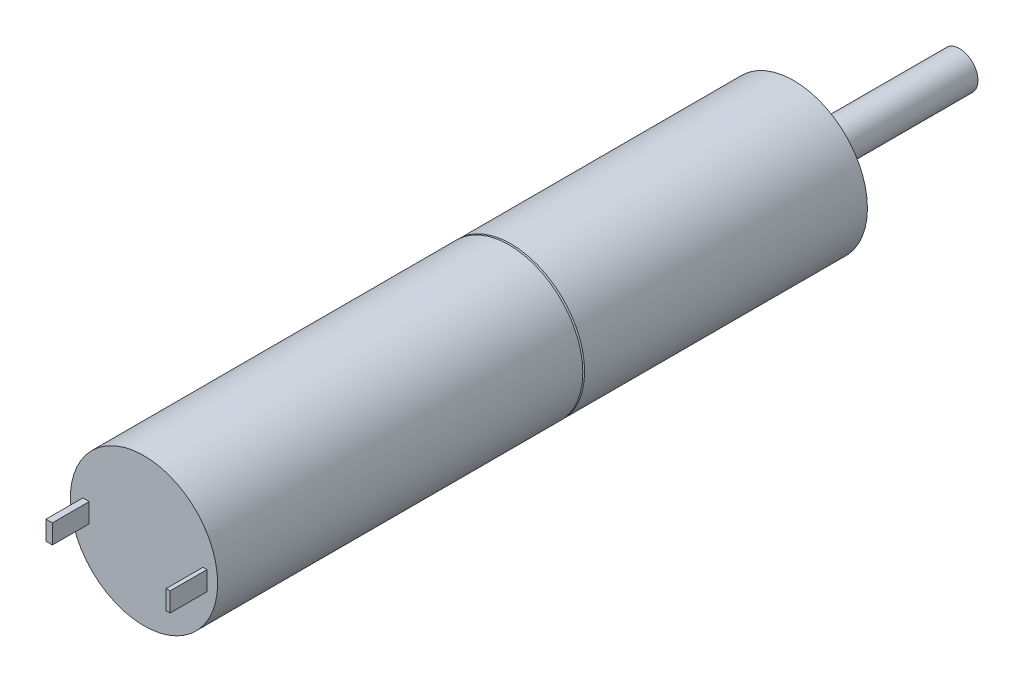
from build123d import *

# Parameters (mm, degrees)
SKETCH1_R           = 6
EXTRUDE1_DEPTH      = 29.8
EXTRUDE1_DEPTH_BACK = 23.1
SKETCH2_W           = 0.322076385
SKETCH2_H           = 1.5639159
SKETCH2_W_2         = 0.519715481
EXTRUDE2_DEPTH      = 3
SKETCH3_R           = 1.5
EXTRUDE3_DEPTH      = 13.5
SKETCH4_R           = 1
CUT_EXTRUDE1_DEPTH  = 13.5


with BuildPart() as part:
    # Sketch1 → Extrude1 (new body, two sides)
    with BuildSketch(Plane.XY) as extrude1_sk:
        Circle(SKETCH1_R)
    extrude(amount=EXTRUDE1_DEPTH)
    extrude(extrude1_sk.sketch, amount=-EXTRUDE1_DEPTH_BACK)

    # Sketch2 → Extrude2 (add)
    with BuildSketch(Plane.XY.offset(29.8)):
        with Locations((4.969715102, -0.2464174)):
            Rectangle(SKETCH2_W, SKETCH2_H)
        with Locations((-4.714918845, -0.2464174)):
            Rectangle(SKETCH2_W_2, SKETCH2_H)
    extrude(amount=EXTRUDE2_DEPTH)

    # Sketch3 → Extrude3 (add)
    with BuildSketch(Plane(origin=(0, 0, -23.1), x_dir=(-1, 0, 0), z_dir=(0, 0, -1))):
        with Locations(Location((0, 0, 0), (0, 0, 180))):  # turned: the seam where the file's is
            Circle(SKETCH3_R)
    extrude(amount=EXTRUDE3_DEPTH)

    # Sketch4 → Cut-Extrude1 (cut)
    with BuildSketch(Plane(origin=(0, 0, -23.1), x_dir=(-1, 0, 0), z_dir=(0, 0, -1))):
        with Locations((4.75, 0)):
            Circle(SKETCH4_R)
        with Locations((-4.75, 0)):
            Circle(SKETCH4_R)
    extrude(amount=-CUT_EXTRUDE1_DEPTH, mode=Mode.SUBTRACT)

    # Sketch6 → Cut-Revolve1 (revolve, cut)
    with BuildSketch(Plane(origin=(0, 0, 0), x_dir=(0, 0, -1), z_dir=(1, 0, 0)), mode=Mode.PRIVATE) as cut_revolve1_sk:
        Polygon((0, 5.8), (0.714830228, 7.76397991), (-0.714830228, 7.76397991), align=None)
    revolve(cut_revolve1_sk.sketch.rotate(Axis((0, 0, 0), (0, 0, 1)), 270), axis=Axis((0, 0, 0), (0, 0, 1)), mode=Mode.SUBTRACT)  # turned: the seam where the file's is


solid = part.part
